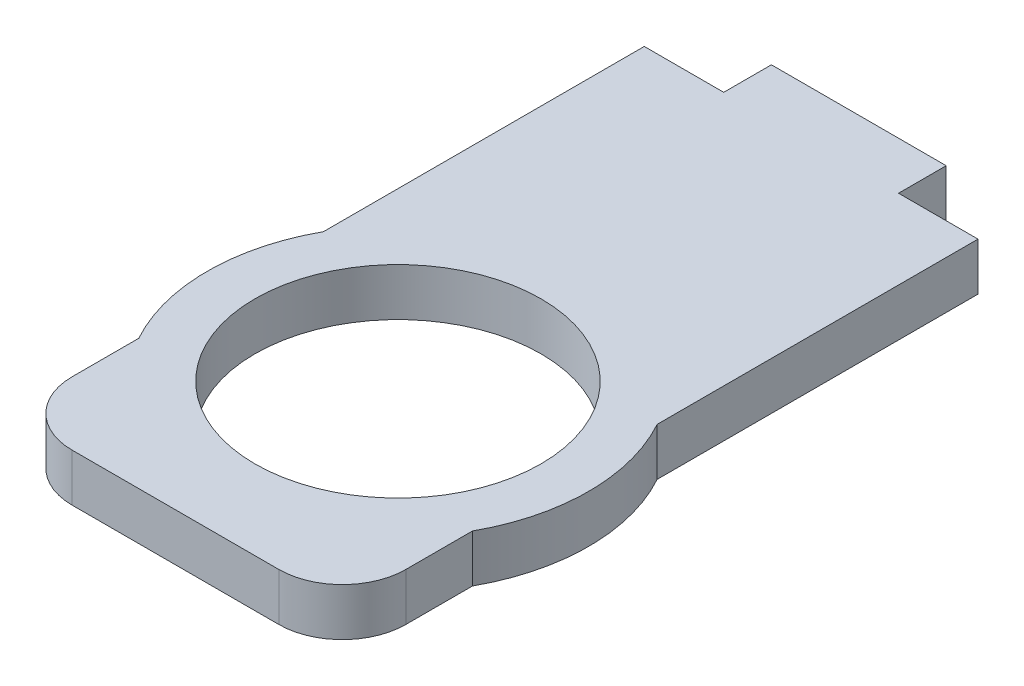
from build123d import *

# Parameters (mm, degrees)
CROQUIS1_W              = 11
CROQUIS1_H              = 3
SALIENTE_EXTRUIR1_DEPTH = 3
CROQUIS2_W              = 21
CROQUIS2_H              = 3
SALIENTE_EXTRUIR2_DEPTH = 40
CROQUIS3_R              = 9
CORTAR_EXTRUIR1_DEPTH   = 10
CROQUIS4_R              = 12
CROQUIS4_R_2            = 9
SALIENTE_EXTRUIR3_DEPTH = 3
REDONDEO1_R             = 4


with BuildPart() as part:
    # Croquis1 → Saliente-Extruir1 (new body)
    with BuildSketch(Plane.XY):
        with Locations((-24.835128068, 47.717862768)):
            Rectangle(CROQUIS1_W, CROQUIS1_H)
    extrude(amount=-SALIENTE_EXTRUIR1_DEPTH)

    # Croquis2 → Saliente-Extruir2 (add)
    with BuildSketch(Plane.XY):
        with Locations((-24.835128068, 47.717862768)):
            Rectangle(CROQUIS2_W, CROQUIS2_H)
    extrude(amount=SALIENTE_EXTRUIR2_DEPTH)

    # Croquis3 → Cortar-Extruir1 (cut)
    with BuildSketch(Plane.XZ.offset(-46.217862768)):
        with Locations((-24.835128068, 26)):
            Circle(CROQUIS3_R)
    extrude(amount=-CORTAR_EXTRUIR1_DEPTH, mode=Mode.SUBTRACT)

    # Croquis4 → Saliente-Extruir3 (add)
    with BuildSketch(Plane(origin=(0, 46.217862768, 0), x_dir=(-1, 0, 0), z_dir=(0, -1, 0))):
        with Locations((24.835128068, -26)):
            Circle(CROQUIS4_R)
        with Locations((24.835128068, -26)):
            Circle(CROQUIS4_R_2, mode=Mode.SUBTRACT)
    extrude(amount=-SALIENTE_EXTRUIR3_DEPTH)

    # Redondeo1
    redondeo1_edges = [part.edges().sort_by_distance(p)[0] for p in [
        (-35.335128068, 47.717862768, 40),
        (-14.335128068, 47.717862768, 40),
    ]]
    fillet(redondeo1_edges, radius=REDONDEO1_R)


solid = part.part
